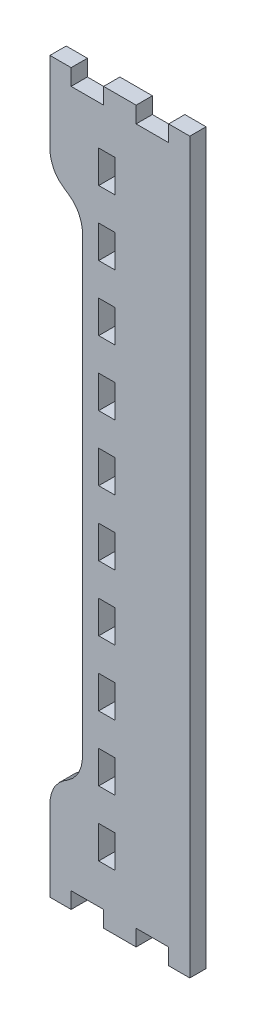
from build123d import *

# Parameters (mm, degrees)
BOSS_EXTRUDE1_DEPTH = 5.715


with BuildPart() as part:
    # Model → Boss-Extrude1 (new body)
    with BuildSketch(Plane.XY):
        Polygon((803.25976, 23.2006394), (810.71212, 23.2006394), (810.71212, 28.91536), (822.14212, 28.91536), (822.14212, 23.2006394), (833.57212, 23.2006394), (833.57212, 28.91536), (845.00212, 28.91536), (845.00212, 23.2006394), (852.4494, 23.2006394), (852.4494, 279.63114), (845.00212, 279.63114), (845.00212, 273.91614), (833.57212, 273.91614), (833.57212, 279.63114), (822.14212, 279.63114), (822.14212, 273.91614), (810.71212, 273.91614), (810.71212, 279.63114), (803.25976, 279.63114), (803.25976, 251.055124), (803.25976, 250.316746), (803.65346, 248.098056), (804.54246, 245.775988), (804.79138, 245.340378), (805.04538, 244.906546), (806.60748, 242.974368), (808.54296, 241.407696), (808.97476, 241.156744), (809.4091, 240.906046), (811.34204, 239.34039), (812.90922, 237.408466), (813.16068, 236.972856), (813.4096, 236.539024), (814.30368, 234.216956), (814.69484, 231.998266), (814.69484, 231.25811), (814.69484, 71.572628), (814.68976, 71.070978), (814.30368, 68.615306), (813.4096, 66.293238), (813.16068, 65.857882), (812.90922, 65.423796), (811.34204, 63.491872), (809.4091, 61.924946), (808.97476, 61.673994), (808.54296, 61.423296), (806.60748, 59.857894), (805.04538, 57.925716), (804.79138, 57.49036), (804.54246, 57.056274), (803.65346, 54.734206), (803.25976, 52.515516), (803.25976, 51.775868), align=None)
        Polygon((820.40984, 254.28448), (820.40984, 259.99948), (826.12484, 259.99948), (826.12484, 248.570496), (820.40984, 248.570496), align=None, mode=Mode.SUBTRACT)
        Polygon((820.40984, 231.424988), (820.40984, 237.141004), (826.12484, 237.141004), (826.12484, 225.710496), (820.40984, 225.710496), align=None, mode=Mode.SUBTRACT)
        Polygon((820.40984, 208.566004), (820.40984, 214.28075), (826.12484, 214.28075), (826.12484, 202.849988), (820.40984, 202.849988), align=None, mode=Mode.SUBTRACT)
        Polygon((820.40984, 185.70575), (820.40984, 191.420496), (826.12484, 191.420496), (826.12484, 179.991004), (820.40984, 179.991004), align=None, mode=Mode.SUBTRACT)
        Polygon((820.40984, 162.845496), (820.40984, 168.560496), (826.12484, 168.560496), (826.12484, 157.13075), (820.40984, 157.13075), align=None, mode=Mode.SUBTRACT)
        Polygon((820.40984, 139.985496), (820.40984, 145.699988), (826.12484, 145.699988), (826.12484, 134.270496), (820.40984, 134.270496), align=None, mode=Mode.SUBTRACT)
        Polygon((820.40984, 117.124988), (820.40984, 122.841004), (826.12484, 122.841004), (826.12484, 111.410496), (820.40984, 111.410496), align=None, mode=Mode.SUBTRACT)
        Polygon((820.40984, 94.266004), (820.40984, 99.98075), (826.12484, 99.98075), (826.12484, 88.549988), (820.40984, 88.549988), align=None, mode=Mode.SUBTRACT)
        Polygon((820.40984, 71.40575), (820.40984, 77.120496), (826.12484, 77.120496), (826.12484, 65.691004), (820.40984, 65.691004), align=None, mode=Mode.SUBTRACT)
        Polygon((820.40984, 48.545496), (820.40984, 54.260496), (826.12484, 54.260496), (826.12484, 42.83075), (820.40984, 42.83075), align=None, mode=Mode.SUBTRACT)
    extrude(amount=BOSS_EXTRUDE1_DEPTH)


solid = part.part
